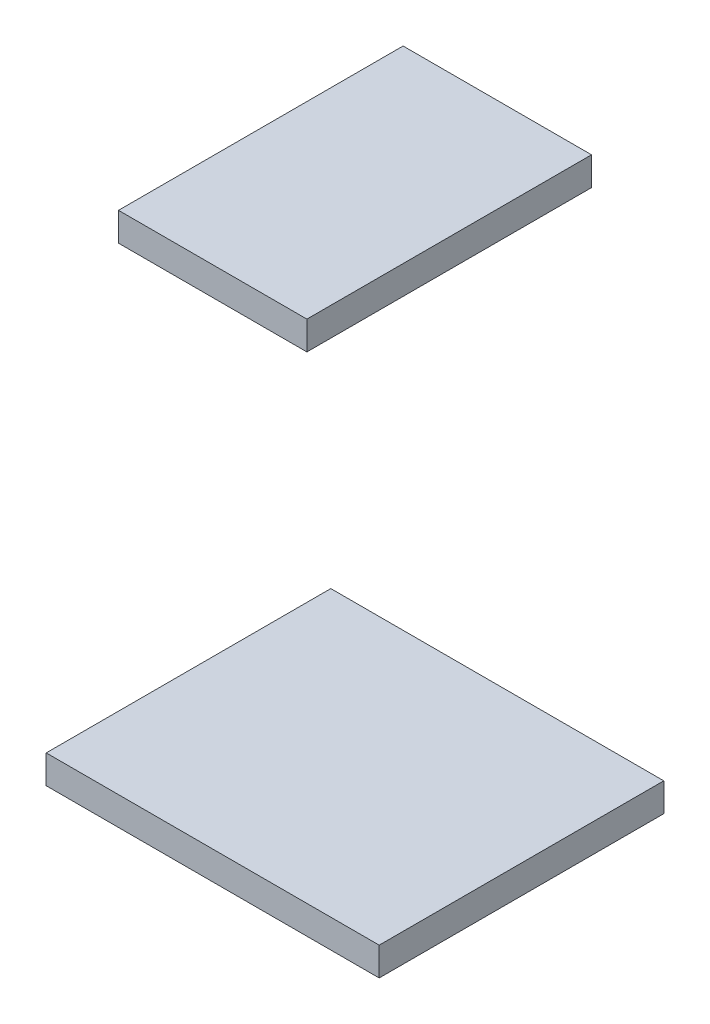
from build123d import *

# Parameters (mm, degrees)
SKIZZE1_W                         = 11.7
SKIZZE1_H                         = 1
AUFSATZ_LINEAR_AUSTRAGEN1_DEPTH   = 10
SKIZZE1_W_2                       = 6.62
AUFSATZ_LINEAR_AUSTRAGEN1_2_DEPTH = 10


with BuildPart() as part:
    # Skizze1 → Aufsatz-Linear austragen1 (new body)
    with BuildSketch(Plane.XY):
        with Locations((96.345, -35.69)):
            Rectangle(SKIZZE1_W, SKIZZE1_H)
    extrude(amount=AUFSATZ_LINEAR_AUSTRAGEN1_DEPTH)


with BuildPart() as body_2:
    # Skizze1 → Aufsatz-Linear austragen1 2 (new body)
    with BuildSketch(Plane.XY):
        with Locations((96.345, -17.91)):
            Rectangle(SKIZZE1_W_2, SKIZZE1_H)
    extrude(amount=AUFSATZ_LINEAR_AUSTRAGEN1_2_DEPTH)


solid = Compound([part.part, body_2.part])
